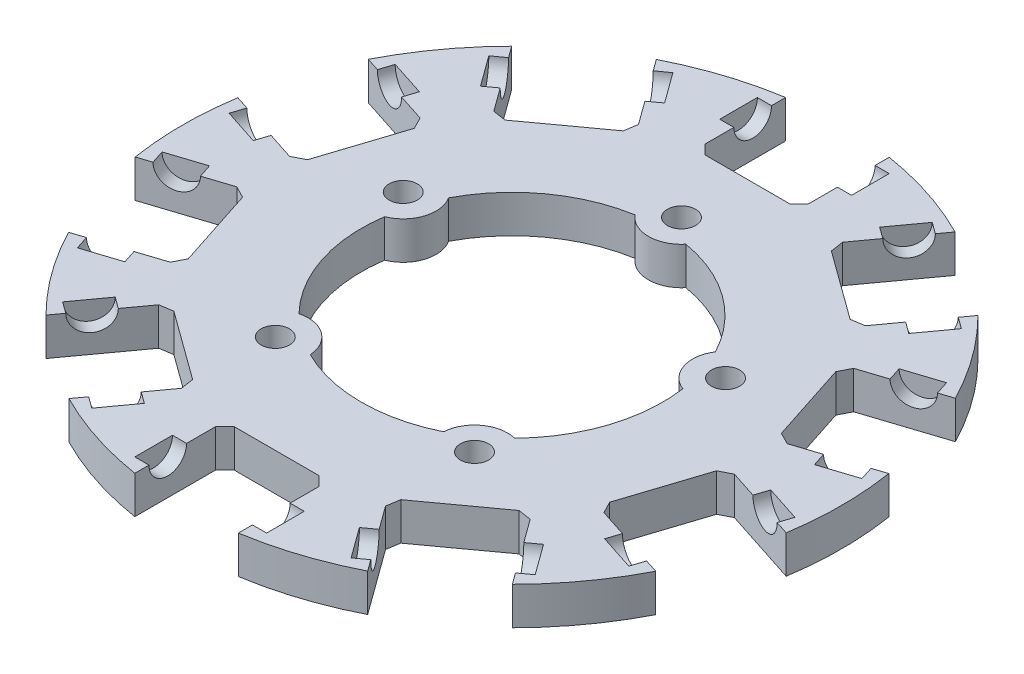
from build123d import *

# Parameters (mm, degrees)
SKIZZE1_R                       = 35
AUFSATZ_LINEAR_AUSTRAGEN1_DEPTH = 4
SCHNITT_LINEAR_AUSTRAGEN1_DEPTH = 5
SKIZZE4_W                       = 14
SKIZZE4_H                       = 2
KREISMUSTER1_COUNT              = 10
SKIZZE5_R                       = 16
SCHNITT_LINEAR_AUSTRAGEN2_DEPTH = 5
SKIZZE7_R                       = 3.5
AUFSATZ_LINEAR_AUSTRAGEN2_DEPTH = 4
SKIZZE6_R                       = 1.5
SCHNITT_LINEAR_AUSTRAGEN3_DEPTH = 5
KREISMUSTER2_COUNT              = 5


with BuildPart() as part:
    # Skizze1 → Aufsatz-Linear austragen1 (new body)
    with BuildSketch(Plane(origin=(0, 0, 0), x_dir=(1, 0, 0), z_dir=(0, 1, 0))):
        Circle(SKIZZE1_R)
    extrude(amount=AUFSATZ_LINEAR_AUSTRAGEN1_DEPTH)

    # Skizze2 → Schnitt-Linear austragen1 (cut, through all)
    with BuildSketch(Plane(origin=(0, 4, 0), x_dir=(1, 0, 0), z_dir=(0, 1, 0))):
        Polygon((-5.5, 37), (-5.5, 26), (-4.5, 25), (0, 25), (4.5, 25), (5.5, 26), (5.5, 37), align=None)
    schnitt_linear_austragen1 = extrude(amount=-SCHNITT_LINEAR_AUSTRAGEN1_DEPTH, mode=Mode.SUBTRACT)

    # Skizze4 → Schnitt-Rotation1 (revolve, cut)
    with BuildSketch(Plane(origin=(0, 4, 0), x_dir=(1, 0, 0), z_dir=(0, 1, 0))):
        with Locations((0, 30.065155865)):
            Rectangle(SKIZZE4_W, SKIZZE4_H)
    schnitt_rotation1 = revolve(axis=Axis((-7, 4, -31.065155865), (1, 0, 0)), mode=Mode.SUBTRACT)

    # Kreismuster1: Schnitt-Linear austragen1, Schnitt-Rotation1 ×10 about axis
    kreismuster1_axis = Axis((0, 0, 0), (0, 1, 0))
    for i in range(1, KREISMUSTER1_COUNT):
        add(schnitt_linear_austragen1.rotate(kreismuster1_axis, i * 360 / KREISMUSTER1_COUNT), mode=Mode.SUBTRACT)
        add(schnitt_rotation1.rotate(kreismuster1_axis, i * 360 / KREISMUSTER1_COUNT), mode=Mode.SUBTRACT)

    # Skizze5 → Schnitt-Linear austragen2 (cut, through all)
    with BuildSketch(Plane(origin=(0, 4, 0), x_dir=(1, 0, 0), z_dir=(0, 1, 0))):
        Circle(SKIZZE5_R)
    extrude(amount=-SCHNITT_LINEAR_AUSTRAGEN2_DEPTH, mode=Mode.SUBTRACT)

    # Skizze7 → Aufsatz-Linear austragen2 (add)
    with BuildSketch(Plane(origin=(0, 0, 0), x_dir=(-1, 0, 0), z_dir=(0, -1, 0))):
        with Locations((0, 18)):
            Circle(SKIZZE7_R)
    aufsatz_linear_austragen2 = extrude(amount=-AUFSATZ_LINEAR_AUSTRAGEN2_DEPTH)

    # Skizze6 → Schnitt-Linear austragen3 (cut, through all)
    with BuildSketch(Plane.XZ):
        with Locations((0, -18)):
            Circle(SKIZZE6_R)
    schnitt_linear_austragen3 = extrude(amount=-SCHNITT_LINEAR_AUSTRAGEN3_DEPTH, mode=Mode.SUBTRACT)

    # Kreismuster2: Aufsatz-Linear austragen2, Schnitt-Linear austragen3 ×5 about axis
    kreismuster2_axis = Axis((0, 0, 0), (0, 1, 0))
    for i in range(1, KREISMUSTER2_COUNT):
        add(aufsatz_linear_austragen2.rotate(kreismuster2_axis, i * 360 / KREISMUSTER2_COUNT))
        add(schnitt_linear_austragen3.rotate(kreismuster2_axis, i * 360 / KREISMUSTER2_COUNT), mode=Mode.SUBTRACT)


solid = part.part
